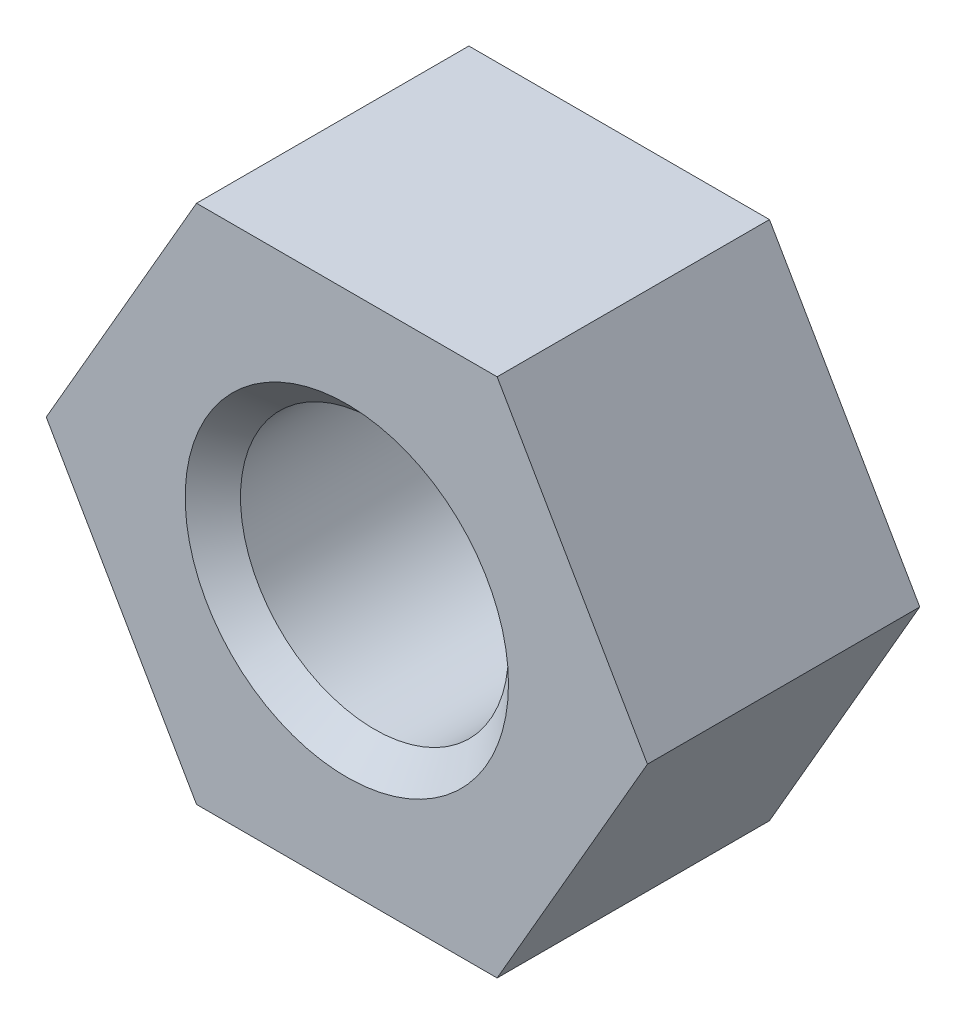
from build123d import *

# Parameters (mm, degrees)
SKETCH_1_R      = 3.3455
EXTRUDE_1_DEPTH = 6.8
CHAMFER_1_SIZE  = 0.6905


with BuildPart() as part:
    # Эскиз1 → Бобышка-Вытянуть1 (new body)
    with BuildSketch(Plane.XY):
        Polygon((-3.75277675, 6.5), (-7.505553499, 0), (-3.75277675, -6.5), (3.75277675, -6.5), (7.505553499, 0), (3.75277675, 6.5), align=None)
        Circle(SKETCH_1_R, mode=Mode.SUBTRACT)
    extrude(amount=EXTRUDE_1_DEPTH)

    # Фаска1
    chamfer_1_edges = [part.edges().sort_by_distance(p)[0] for p in [
        (-3.3455, 0, 0),
        (-3.3455, 0, 6.8),
    ]]
    chamfer(chamfer_1_edges, length=CHAMFER_1_SIZE)


solid = part.part
